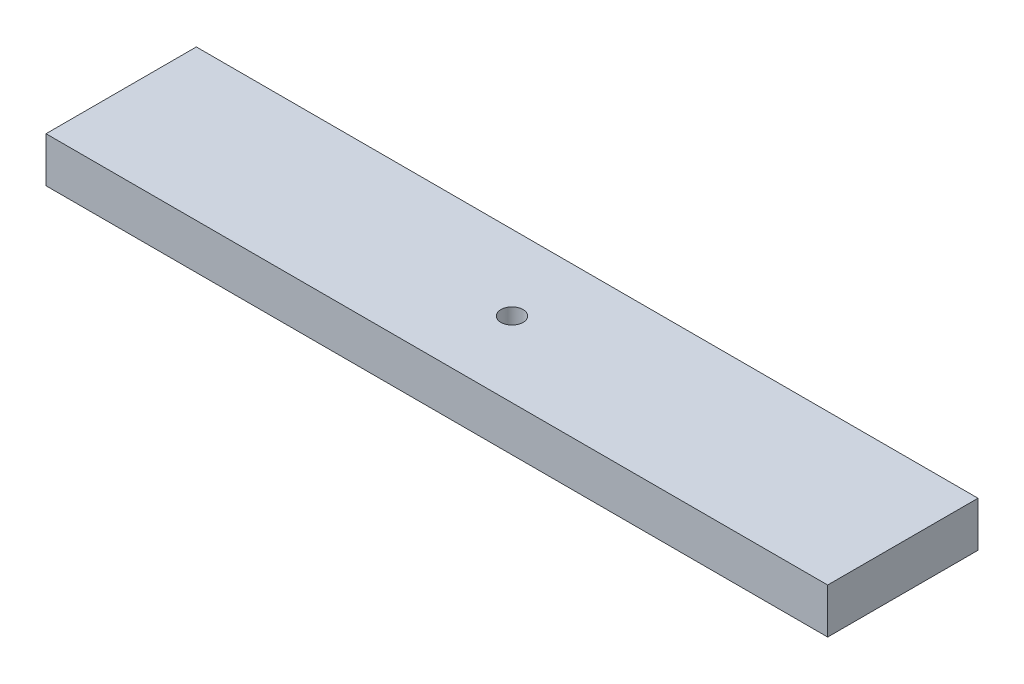
from build123d import *

# Parameters (mm, degrees)
SKETCH2_W           = 330.2
SKETCH2_H           = 19.05
BOSS_EXTRUDE1_DEPTH = 63.5
SKETCH4_R           = 4.699
CUT_EXTRUDE2_DEPTH  = 20.05


with BuildPart() as part:
    # Sketch2 → Boss-Extrude1 (new body)
    with BuildSketch(Plane.XY):
        with Locations((0, 9.525)):
            Rectangle(SKETCH2_W, SKETCH2_H)
    extrude(amount=BOSS_EXTRUDE1_DEPTH)

    # Sketch4 → Cut-Extrude2 (cut, through all)
    with BuildSketch(Plane(origin=(0, 0, 0), x_dir=(1, 0, 0), z_dir=(0, 1, 0))):
        with Locations((0, -31.75)):
            Circle(SKETCH4_R)
    extrude(amount=CUT_EXTRUDE2_DEPTH, mode=Mode.SUBTRACT)


solid = part.part
